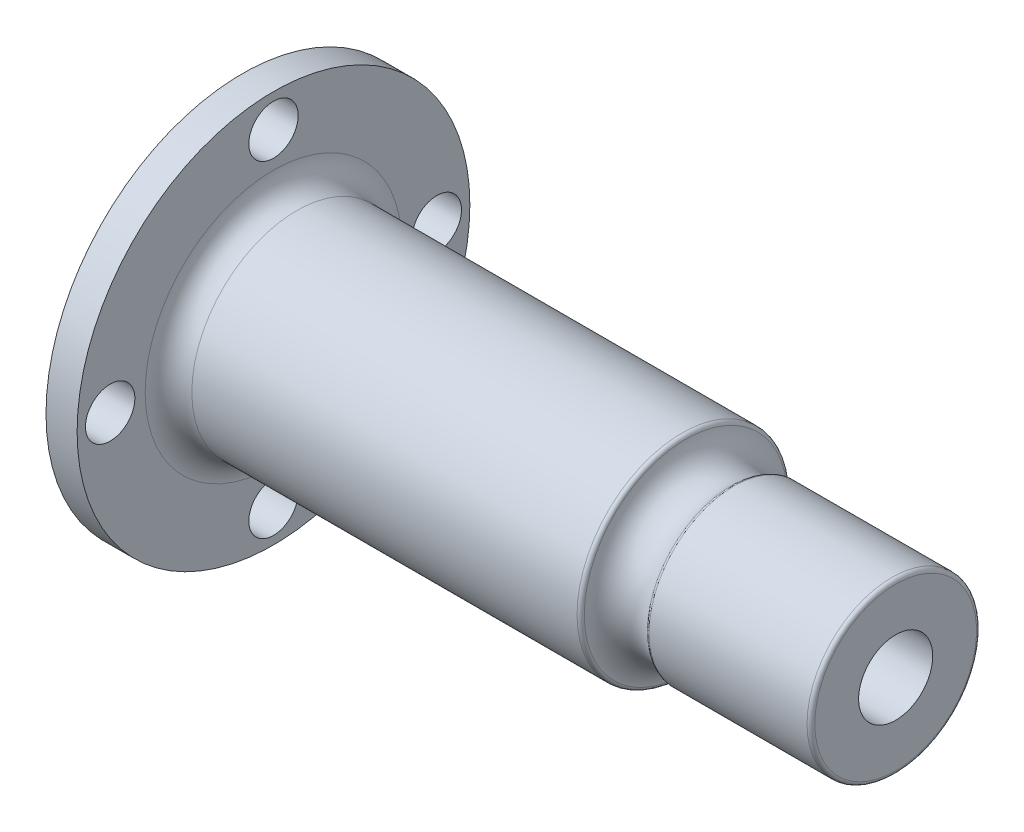
from build123d import *

# Parameters (mm, degrees)
FILLET1_R          = 0.5
FILLET2_R          = 3
SKETCH3_R          = 4.7625
CUT_EXTRUDE1_DEPTH = 92.514851485
SKETCH4_R          = 3.175
CUT_EXTRUDE3_DEPTH = 135.6


with BuildPart() as part:
    # Sketch1 → Revolve1 (revolve)
    with BuildSketch(Plane.XY):
        with BuildLine():
            Line((134.6, 0), (134.6, 10.9))
            Line((134.6, 10.9), (113.6, 10.9))
            ThreePointArc((113.6, 10.9), (109.746525497, 10.230443455), (107.6, 13.5))
            Line((107.6, 13.5), (54.6, 13.5))
            Line((54.6, 13.5), (54.6, 27.5))
            Line((54.6, 27.5), (47.6, 27.5))
            Line((47.6, 27.5), (47.6, 32.25))
            Line((47.6, 32.25), (44.6, 32.25))
            Line((44.6, 32.25), (44.6, 37))
            Line((44.6, 37), (40.6, 37))
            Line((40.6, 37), (40.6, 42))
            Line((40.6, 42), (23, 42))
            Line((23, 42), (23, 43))
            Line((23, 43), (5, 43))
            Line((5, 43), (5, 44))
            Line((5, 44), (0, 44))
            Line((0, 44), (0, 0))
            Line((0, 0), (134.6, 0))
        make_face()
    revolve(axis=Axis((-159.727345132, 0, 0), (1, 0, 0)))

    # Fillet1
    fillet1_edges = [part.edges().sort_by_distance(p)[0] for p in [
        (5, -43, 0),
        (23, -42, 0),
        (40.6, -42, 0),
        (40.6, -37, 0),
        (44.6, -37, 0),
        (44.6, -32.25, 0),
        (47.6, -32.25, 0),
        (47.6, -27.5, 0),
        (54.6, -27.5, 0),
        (107.6, -13.5, 0),
        (113.6, -10.9, 0),
        (134.6, -10.9, 0),
    ]]
    fillet(fillet1_edges, radius=FILLET1_R)

    # Fillet2
    fillet2_edges = [part.edges().sort_by_distance(p)[0] for p in [
        (54.6, -13.5, 0),
    ]]
    fillet(fillet2_edges, radius=FILLET2_R)

    # Sketch2 → Cut-Revolve1 (revolve, cut)
    with BuildSketch(Plane.XY):
        Polygon((50.6, 25.25), (64.002595821, 25.25), (64.002595821, 54.446385227), (-9.354779202, 54.446385227), (-9.354779202, 0), (39.6, 0), (43.085148515, 0), (43.085148515, 8), align=None)
    revolve(axis=Axis((-12.93677823, 0, 0), (1, 0, 0)), mode=Mode.SUBTRACT)

    # Sketch3 → Cut-Extrude1 (cut, through all)
    with BuildSketch(Plane(origin=(134.6, 0, 0), x_dir=(0, 0, -1), z_dir=(1, 0, 0))):
        Circle(SKETCH3_R)
    extrude(amount=-CUT_EXTRUDE1_DEPTH, mode=Mode.SUBTRACT)

    # Sketch4 → Cut-Extrude3 (cut, through all)
    with BuildSketch(Plane(origin=(0, 0, 0), x_dir=(0, 0, -1), z_dir=(1, 0, 0))):
        with Locations((21, 0)):
            Circle(SKETCH4_R)
        with Locations((0, -21)):
            Circle(SKETCH4_R)
        with Locations((0, 21)):
            Circle(SKETCH4_R)
        with Locations((-21, 0)):
            Circle(SKETCH4_R)
    extrude(amount=CUT_EXTRUDE3_DEPTH, mode=Mode.SUBTRACT)


solid = part.part
